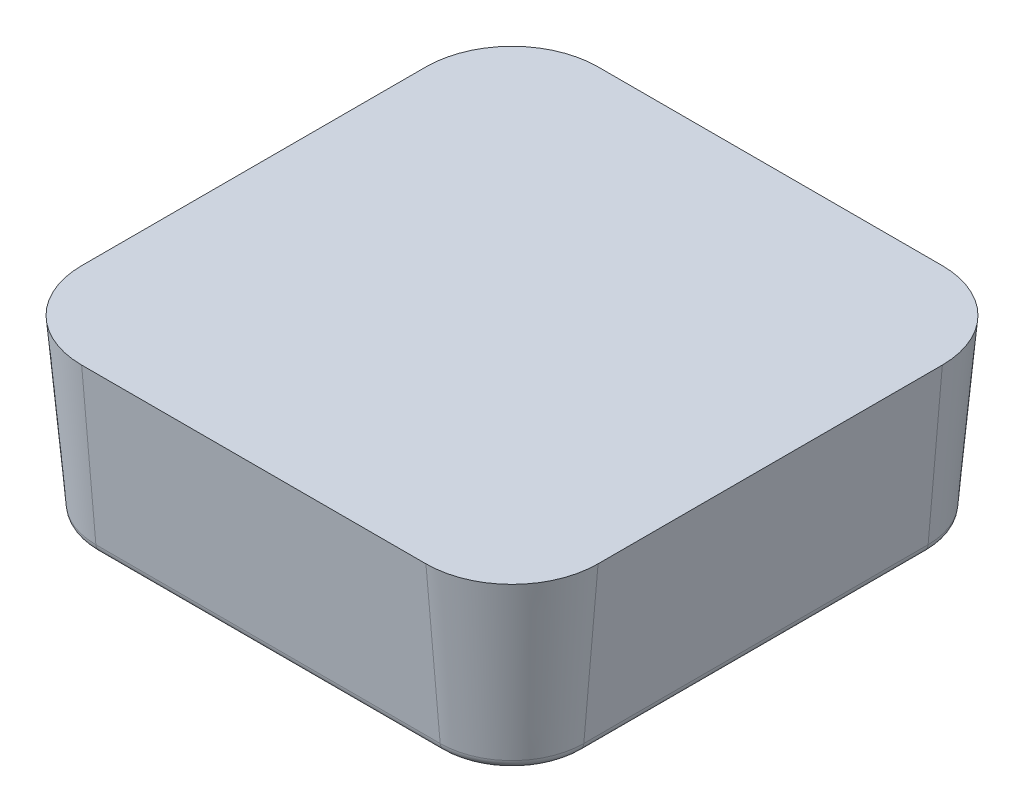
from build123d import *

# Parameters (mm, degrees)
BOSS_EXTRUDE1_DEPTH = 6.35
BOSS_EXTRUDE1_DRAFT = -5
CUT_EXTRUDE3_DEPTH  = 15.892070037
CIRPATTERN3_COUNT   = 12
BOSS_EXTRUDE3_DEPTH = 6.35
BOSS_EXTRUDE3_DRAFT = -5
FILLET2_R           = 0.381
BOSS_EXTRUDE4_REACH = 16.734
SKETCH8_R           = 1.1811
SKETCH9_R           = 1.1811
CUT_EXTRUDE4_DEPTH  = 15.73364215
CIRPATTERN4_COUNT   = 4


with BuildPart() as part:
    # Sketch1 → Boss-Extrude1 (with draft: the straight prism first)
    with BuildSketch(Plane(origin=(0, 0, 0), x_dir=(1, 0, 0), z_dir=(0, 1, 0))):
        with BuildLine():
            Line((-6.35, -9.525), (6.35, -9.525))
            ThreePointArc((6.35, -9.525), (8.59506403, -8.59506403), (9.525, -6.35))
            Line((9.525, -6.35), (9.525, 6.35))
            ThreePointArc((9.525, 6.35), (8.59506403, 8.59506403), (6.35, 9.525))
            Line((6.35, 9.525), (-6.35, 9.525))
            ThreePointArc((-6.35, 9.525), (-8.59506403, 8.59506403), (-9.525, 6.35))
            Line((-9.525, 6.35), (-9.525, -6.35))
            ThreePointArc((-9.525, -6.35), (-8.59506403, -8.59506403), (-6.35, -9.525))
        make_face()
    extrude(amount=-BOSS_EXTRUDE1_DEPTH)
    # Boss-Extrude1: the draft: its side faces are tilted about the plane it starts from
    boss_extrude1_sides = [part.faces().sort_by_distance(p)[0] for p in [
        (-8.59506403, -3.175, 8.59506403),
        (0, -3.175, 9.525),
        (8.59506403, -3.175, 8.59506403),
        (9.525, -3.175, 0),
        (8.59506403, -3.175, -8.59506403),
        (0, -3.175, -9.525),
        (-8.59506403, -3.175, -8.59506403),
        (-9.525, -3.175, 0),
    ]]
    draft(boss_extrude1_sides, Plane(origin=(0, 0, 0), x_dir=(1, 0, 0), z_dir=(0, 1, 0)), BOSS_EXTRUDE1_DRAFT)

    # Sketch6 → Cut-Extrude3 (cut, through all)
    with BuildSketch(Plane(origin=(0, 0, 0), x_dir=(0.9659258262890681, 0, 0.25881904510252135), z_dir=(-0.25881904510252135, 0, 0.9659258262890681))):
        Polygon((0, -2.159), (-7.366, -9.525), (7.366, -9.525), align=None)
    cut_extrude3 = extrude(amount=-CUT_EXTRUDE3_DEPTH, mode=Mode.SUBTRACT)

    # CirPattern3: Cut-Extrude3 ×12 about axis
    cirpattern3_axis = Axis((0, 0, 0), (0, 1, 0))
    for i in range(1, CIRPATTERN3_COUNT):
        add(cut_extrude3.rotate(cirpattern3_axis, i * 360 / CIRPATTERN3_COUNT), mode=Mode.SUBTRACT)


with BuildPart() as boss_extrude3_tool:
    # Sketch7 → Boss-Extrude3 (with draft: the straight prism first)
    with BuildSketch(Plane(origin=(0, 0, 0), x_dir=(1, 0, 0), z_dir=(0, 1, 0))):
        with BuildLine():
            Line((-6.35, -9.525), (6.35, -9.525))
            ThreePointArc((6.35, -9.525), (8.59506403, -8.59506403), (9.525, -6.35))
            Line((9.525, -6.35), (9.525, 6.35))
            ThreePointArc((9.525, 6.35), (8.59506403, 8.59506403), (6.35, 9.525))
            Line((6.35, 9.525), (-6.35, 9.525))
            ThreePointArc((-6.35, 9.525), (-8.59506403, 8.59506403), (-9.525, 6.35))
            Line((-9.525, 6.35), (-9.525, -6.35))
            ThreePointArc((-9.525, -6.35), (-8.59506403, -8.59506403), (-6.35, -9.525))
        make_face()
        with BuildLine():
            Line((-6.35, -7.493), (6.35, -7.493))
            ThreePointArc((6.35, -7.493), (7.158223051, -7.158223051), (7.493, -6.35))
            Line((7.493, -6.35), (7.493, 6.35))
            ThreePointArc((7.493, 6.35), (7.158223051, 7.158223051), (6.35, 7.493))
            Line((6.35, 7.493), (-6.35, 7.493))
            ThreePointArc((-6.35, 7.493), (-7.158223051, 7.158223051), (-7.493, 6.35))
            Line((-7.493, 6.35), (-7.493, -6.35))
            ThreePointArc((-7.493, -6.35), (-7.158223051, -7.158223051), (-6.35, -7.493))
        make_face(mode=Mode.SUBTRACT)
    extrude(amount=-BOSS_EXTRUDE3_DEPTH)
    # Boss-Extrude3: the draft: its side faces are tilted about the plane it starts from
    boss_extrude3_sides = [boss_extrude3_tool.faces().sort_by_distance(p)[0] for p in [
        (0, -3.175, 9.525),
        (8.59506403, -3.175, 8.59506403),
        (9.525, -3.175, 0),
        (8.59506403, -3.175, -8.59506403),
        (0, -3.175, -9.525),
        (-8.59506403, -3.175, -8.59506403),
        (-9.525, -3.175, 0),
        (-8.59506403, -3.175, 8.59506403),
        (-7.158223051, -3.175, 7.158223051),
        (-7.493, -3.175, 0),
        (-7.158223051, -3.175, -7.158223051),
        (0, -3.175, -7.493),
        (7.158223051, -3.175, -7.158223051),
        (7.493, -3.175, 0),
        (7.158223051, -3.175, 7.158223051),
        (0, -3.175, 7.493),
    ]]
    draft(boss_extrude3_sides, Plane(origin=(0, 0, 0), x_dir=(1, 0, 0), z_dir=(0, 1, 0)), BOSS_EXTRUDE3_DRAFT)


with BuildPart() as part_1:
    add(part.part)

    # Boss-Extrude3: add boss_extrude3_tool
    add(boss_extrude3_tool.part)

    # Fillet2
    fillet2_edges = [part_1.edges().sort_by_distance(p)[0] for p in [
        (8.202228727, -6.35, -8.202228727),
        (8.202228727, -6.35, 8.202228727),
        (-8.202228727, -6.35, 8.202228727),
        (-8.202228727, -6.35, -8.202228727),
        (-8.969446987, -6.35, 0),
        (0, -6.35, -8.969446987),
        (0, -6.35, 8.969446987),
        (8.969446987, -6.35, 0),
        (-8.048553013, -6.35, 0),
        (-7.551058354, -6.35, 7.551058354),
        (0, -6.35, 8.048553013),
        (7.551058354, -6.35, 7.551058354),
        (8.048553013, -6.35, 0),
        (7.551058354, -6.35, -7.551058354),
        (0, -6.35, -8.048553013),
        (-7.551058354, -6.35, -7.551058354),
    ]]
    fillet(fillet2_edges, radius=FILLET2_R)

    # Sketch8 → Boss-Extrude4 (add, up to next)
    with BuildSketch(Plane(origin=(0, -5.969, 0), x_dir=(-1, 0, 0), z_dir=(0, -1, 0)), mode=Mode.PRIVATE) as boss_extrude4_sk1:
        with Locations((0, 7.493)):
            Circle(SKETCH8_R)
    boss_extrude4_tool1 = extrude(boss_extrude4_sk1.sketch, amount=-BOSS_EXTRUDE4_REACH, mode=Mode.PRIVATE) - part_1.part
    boss_extrude4 = boss_extrude4_tool1.solids().sort_by_distance((0, -5.969, -7.493))[0]
    add(boss_extrude4)

    # Sketch9 → Cut-Extrude4 (cut, through all)
    with BuildSketch(Plane.XZ.offset(5.969)):
        with Locations((0, -7.493)):
            Circle(SKETCH9_R)
    cut_extrude4 = extrude(amount=CUT_EXTRUDE4_DEPTH, mode=Mode.SUBTRACT)

    # CirPattern4: Boss-Extrude4, Cut-Extrude4 ×4 about axis
    cirpattern4_axis = Axis((0, 0, 0), (0, 1, 0))
    add([boss_extrude4.rotate(cirpattern4_axis, i * 360 / CIRPATTERN4_COUNT) for i in range(1, CIRPATTERN4_COUNT)])
    add([cut_extrude4.rotate(cirpattern4_axis, i * 360 / CIRPATTERN4_COUNT) for i in range(1, CIRPATTERN4_COUNT)], mode=Mode.SUBTRACT)


solid = part_1.part
